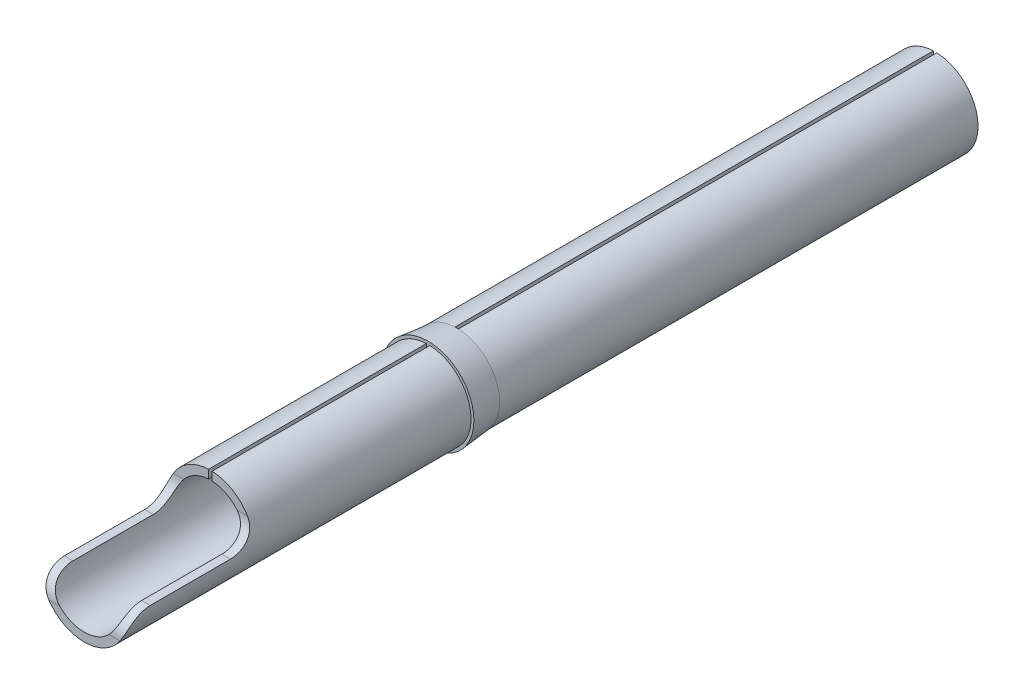
from build123d import *

# Parameters (mm, degrees)
SKETCH1_R           = 0.75
BOSS_EXTRUDE1_DEPTH = 5.1
SKETCH8_R           = 0.75
BOSS_EXTRUDE2_DEPTH = 1.75
SKETCH9_R           = 0.75
BOSS_EXTRUDE3_DEPTH = 8
SKETCH10_R          = 0.6
CUT_EXTRUDE7_DEPTH  = 5.65
SKETCH11_R          = 0.5
CUT_EXTRUDE8_DEPTH  = 6.5
CUT_EXTRUDE9_DEPTH  = 14.85
CUT_EXTRUDE10_DEPTH = 6.5
FILLET2_R           = 0.15
CUT_EXTRUDE11_DEPTH = 2.2
FILLET3_R           = 0.4
SKETCH17_R          = 0.75
SKETCH16_R          = 0.8


with BuildPart() as part:
    # Sketch1 → Boss-Extrude1 (new body)
    with BuildSketch(Plane.XY):
        Circle(SKETCH1_R)
    extrude(amount=BOSS_EXTRUDE1_DEPTH)

    # Sketch8 → Boss-Extrude2 (add)
    with BuildSketch(Plane.XY.offset(5.1)):
        Circle(SKETCH8_R)
    extrude(amount=BOSS_EXTRUDE2_DEPTH)

    # Sketch9 → Boss-Extrude3 (add)
    with BuildSketch(Plane.XY.offset(6.85)):
        Circle(SKETCH9_R)
    extrude(amount=BOSS_EXTRUDE3_DEPTH)

    # Sketch10 → Cut-Extrude7 (cut)
    with BuildSketch(Plane.XY.offset(14.85)):
        Circle(SKETCH10_R)
    extrude(amount=-CUT_EXTRUDE7_DEPTH, mode=Mode.SUBTRACT)

    # Sketch11 → Cut-Extrude8 (cut)
    with BuildSketch(Plane(origin=(0, 0, 0), x_dir=(-1, 0, 0), z_dir=(0, 0, -1))):
        Circle(SKETCH11_R)
    extrude(amount=-CUT_EXTRUDE8_DEPTH, mode=Mode.SUBTRACT)

    # Sketch12 → Cut-Extrude9 (cut)
    with BuildSketch(Plane.XY.offset(14.85)):
        with BuildLine():
            Line((-0.03, 0.74939976), (-0.03, 0.599249531))
            ThreePointArc((-0.03, 0.599249531), (0, 0.6), (0.03, 0.599249531))
            Line((0.03, 0.599249531), (0.03, 0.74939976))
            ThreePointArc((0.03, 0.74939976), (0, 0.75), (-0.03, 0.74939976))
        make_face()
    extrude(amount=-CUT_EXTRUDE9_DEPTH, mode=Mode.SUBTRACT)

    # Sketch14 → Cut-Extrude10 (cut)
    with BuildSketch(Plane(origin=(0, 0, 0), x_dir=(-1, 0, 0), z_dir=(0, 0, -1))):
        with BuildLine():
            Line((-0.03, 0.74939976), (-0.03, 0.499099189))
            ThreePointArc((-0.03, 0.499099189), (0, 0.5), (0.03, 0.499099189))
            Line((0.03, 0.499099189), (0.03, 0.74939976))
            ThreePointArc((0.03, 0.74939976), (0, 0.75), (-0.03, 0.74939976))
        make_face()
    extrude(amount=-CUT_EXTRUDE10_DEPTH, mode=Mode.SUBTRACT)

    # Fillet2
    fillet2_edges = [part.edges().sort_by_distance(p)[0] for p in [
        (0.34278273, -0.364005494, 0),
    ]]
    fillet(fillet2_edges, radius=FILLET2_R)

    # Sketch15 → Cut-Extrude11 (cut)
    with BuildSketch(Plane.XY.offset(14.85)):
        with BuildLine():
            Line((-0.749733286, -0.02), (-0.599666574, -0.02))
            ThreePointArc((-0.599666574, -0.02), (-0.441573883, 0.406217314), (-0.03, 0.599249531))
            Line((-0.03, 0.599249531), (-0.03, 0.74939976))
            ThreePointArc((-0.03, 0.74939976), (-0.547713426, 0.5123573), (-0.749733286, -0.02))
        make_face()
        with BuildLine():
            Line((0.03, 0.599249531), (0.03, 0.74939976))
            ThreePointArc((0.03, 0.74939976), (0.547713426, 0.5123573), (0.749733286, -0.02))
            Line((0.749733286, -0.02), (0.599666574, -0.02))
            ThreePointArc((0.599666574, -0.02), (0.441573883, 0.406217314), (0.03, 0.599249531))
        make_face()
    extrude(amount=-CUT_EXTRUDE11_DEPTH, mode=Mode.SUBTRACT)

    # Fillet3
    fillet3_edges = [part.edges().sort_by_distance(p)[0] for p in [
        (-0.67469993, -0.02, 12.65),
        (-0.67469993, -0.02, 14.85),
        (0.67469993, -0.02, 12.65),
        (0.67469993, -0.02, 14.85),
    ]]
    fillet(fillet3_edges, radius=FILLET3_R)

    # Sketch17 → Loft1 section 0
    with BuildSketch(Plane.XY.offset(8.35)):
        Circle(SKETCH17_R)
    # Sketch16 → Loft1 section 1
    with BuildSketch(Plane.XY.offset(8.85)):
        Circle(SKETCH16_R)
    loft()


solid = part.part
